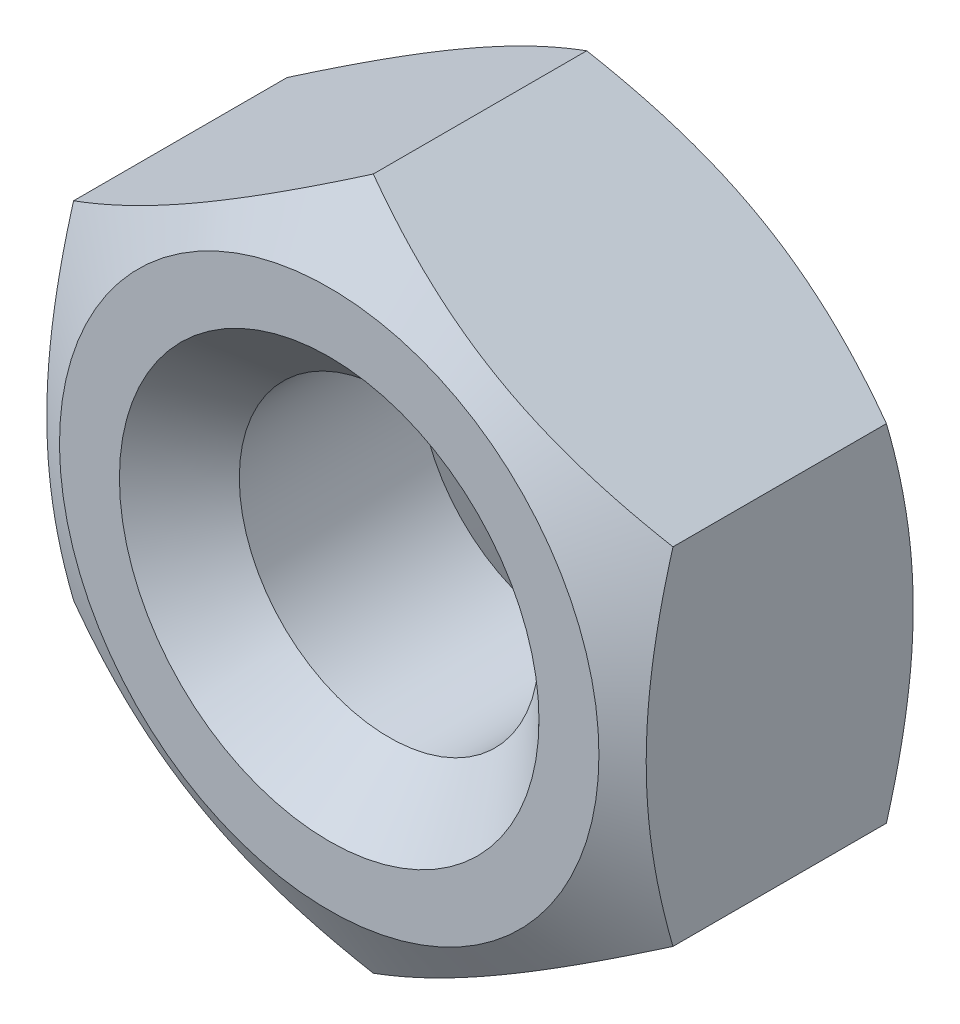
from build123d import *

# Parameters (mm, degrees)
SKETCH_1_W               = 5
SKETCH_1_H               = 2
SKETCH_2_OUTSIDE_W       = 14.856
SKETCH_2_OUTSIDE_H       = 14.856
CUT_EXTRUDE_1_DEPTH      = 2
SKETCH_3_R               = 1
CUT_EXTRUDE_2_DEPTH      = 1
CUT_EXTRUDE_2_DEPTH_BACK = 3
CHAMFER_1_SIZE           = 0.4


with BuildPart() as part:
    # Эскиз1 → Повернуть1 (revolve)
    with BuildSketch(Plane(origin=(0, 0, 0), x_dir=(1, 0, 0), z_dir=(0, 1, 0))):
        with Locations((-2.5, 1)):
            Rectangle(SKETCH_1_W, SKETCH_1_H)
    revolve(axis=Axis((0, 0, 0), (0, 0, -1)))

    # Эскиз2 outside → Вырез-Вытянуть1 (cut)
    with BuildSketch(Plane.XY):
        Rectangle(SKETCH_2_OUTSIDE_W, SKETCH_2_OUTSIDE_H)
        Polygon((2, -1.154700538), (2, 1.154700538), (0, 2.309401077), (-2, 1.154700538), (-2, -1.154700538), (0, -2.309401077), align=None, mode=Mode.SUBTRACT)
    extrude(amount=-CUT_EXTRUDE_1_DEPTH, mode=Mode.SUBTRACT)

    # Эскиз3 → Вырез-Вытянуть2 (cut, two sides)
    with BuildSketch(Plane.XY) as cut_extrude_2_sk:
        Circle(SKETCH_3_R)
    extrude(amount=CUT_EXTRUDE_2_DEPTH, mode=Mode.SUBTRACT)
    extrude(cut_extrude_2_sk.sketch, amount=-CUT_EXTRUDE_2_DEPTH_BACK, mode=Mode.SUBTRACT)

    # Эскиз4 → Вырез-Повернуть1 (revolve, cut)
    with BuildSketch(Plane(origin=(0, 0, 0), x_dir=(0, 0, -1), z_dir=(1, 0, 0))):
        Polygon((0, 1.8), (0.294102849, 2.309401077), (0, 2.309401077), align=None)
        Polygon((2.008215931, 1.807483823), (1.714113082, 2.3168849), (2.008215931, 2.3168849), align=None)
    revolve(axis=Axis((0, 0, 0), (0, 0, -1)), mode=Mode.SUBTRACT)

    # Фаска1
    chamfer_1_edges = [part.edges().sort_by_distance(p)[0] for p in [
        (-1, 0, -2),
        (-1, 0, 0),
    ]]
    chamfer(chamfer_1_edges, length=CHAMFER_1_SIZE)


solid = part.part
